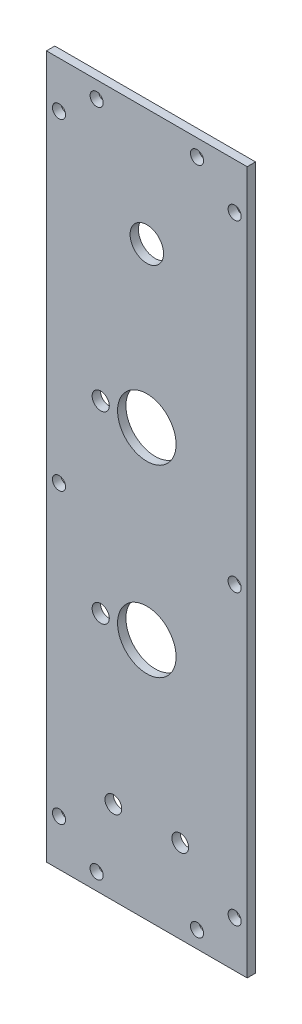
from build123d import *

# Parameters (mm, degrees)
SKETCH1_W           = 76.2
SKETCH1_H           = 266.7
SKETCH1_R           = 2.4892
BOSS_EXTRUDE1_DEPTH = 3.175
SKETCH2_R           = 11.1125
SKETCH2_R_2         = 3.2512
SKETCH2_R_3         = 3.175
SKETCH2_R_4         = 6.35
CUT_EXTRUDE1_DEPTH  = 3.175


with BuildPart() as part:
    # Sketch1 → Boss-Extrude1 (new body)
    with BuildSketch(Plane.XY):
        with Locations((38.1, -133.35)):
            Rectangle(SKETCH1_W, SKETCH1_H)
        with Locations((19.05, -6.35)):
            Circle(SKETCH1_R, mode=Mode.SUBTRACT)
        with Locations((57.15, -6.35)):
            Circle(SKETCH1_R, mode=Mode.SUBTRACT)
        with Locations((71.4375, -17.4625)):
            Circle(SKETCH1_R, mode=Mode.SUBTRACT)
        with Locations((4.7625, -17.4625)):
            Circle(SKETCH1_R, mode=Mode.SUBTRACT)
        with Locations((71.4375, -139.7)):
            Circle(SKETCH1_R, mode=Mode.SUBTRACT)
        with Locations((4.7625, -139.7)):
            Circle(SKETCH1_R, mode=Mode.SUBTRACT)
        with Locations((71.4375, -249.2375)):
            Circle(SKETCH1_R, mode=Mode.SUBTRACT)
        with Locations((4.7625, -249.2375)):
            Circle(SKETCH1_R, mode=Mode.SUBTRACT)
        with Locations((19.05, -260.35)):
            Circle(SKETCH1_R, mode=Mode.SUBTRACT)
        with Locations((57.15, -260.35)):
            Circle(SKETCH1_R, mode=Mode.SUBTRACT)
    extrude(amount=BOSS_EXTRUDE1_DEPTH)

    # Sketch2 → Cut-Extrude1 (cut)
    with BuildSketch(Plane.XY.offset(3.175)):
        with Locations((38.1, -104.775)):
            Circle(SKETCH2_R)
        with Locations((38.1, -174.625)):
            Circle(SKETCH2_R)
        with Locations((20.599908, -174.625)):
            Circle(SKETCH2_R_2)
        with Locations((20.599908, -104.775)):
            Circle(SKETCH2_R_2)
        with Locations((25.4, -234.95)):
            Circle(SKETCH2_R_3)
        with Locations((50.8, -234.95)):
            Circle(SKETCH2_R_3)
        with Locations((38.1, -44.45)):
            Circle(SKETCH2_R_4)
    extrude(amount=-CUT_EXTRUDE1_DEPTH, mode=Mode.SUBTRACT)


solid = part.part
